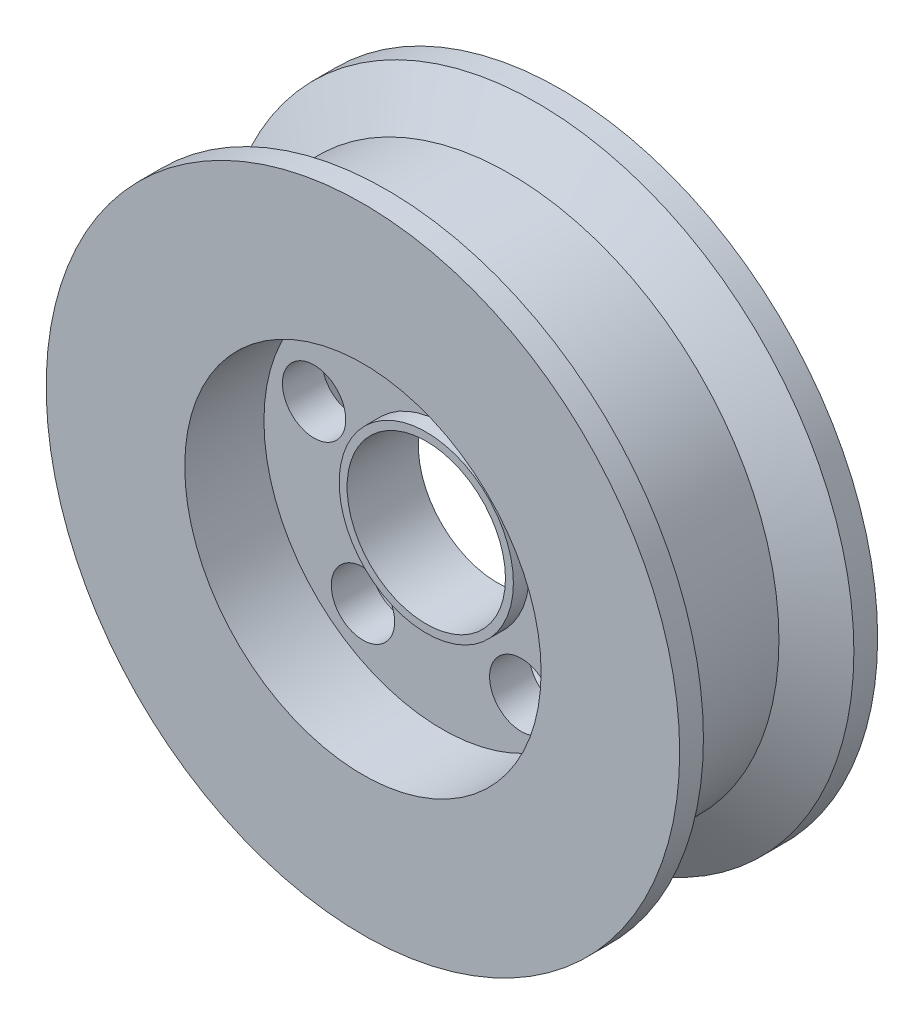
from build123d import *

# Parameters (mm, degrees)
SKETCH1_R                = 40
SKETCH1_R_2              = 10
BOSS_EXTRUDE1_DEPTH      = 12.5
SKETCH2_R                = 22.5
CUT_EXTRUDE1_DEPTH       = 10
SKETCH3_R                = 4
CUT_EXTRUDE2_DEPTH       = 16
CIRPATTERN1_COUNT        = 5
SKETCH4_R                = 11
SKETCH4_R_2              = 10
BOSS_EXTRUDE2_DEPTH      = 2
BOSS_EXTRUDE2_DEPTH_BACK = 7


with BuildPart() as part:
    # Sketch1 → Boss-Extrude1 (new body, symmetric)
    with BuildSketch(Plane.XY):
        Circle(SKETCH1_R)
        Circle(SKETCH1_R_2, mode=Mode.SUBTRACT)
    extrude(amount=BOSS_EXTRUDE1_DEPTH, both=True)

    # Sketch2 → Cut-Extrude1 (cut)
    with BuildSketch(Plane.XY.offset(12.5)):
        Circle(SKETCH2_R)
    cut_extrude1 = extrude(amount=-CUT_EXTRUDE1_DEPTH, mode=Mode.SUBTRACT)

    # Mirror1: Cut-Extrude1 across plane
    add(cut_extrude1.mirror(Plane.XY), mode=Mode.SUBTRACT)

    # Sketch3 → Cut-Extrude2 (cut, through all)
    with BuildSketch(Plane.XY.offset(2.5)):
        with Locations((0, 17)):
            Circle(SKETCH3_R)
    cut_extrude2 = extrude(amount=-CUT_EXTRUDE2_DEPTH, mode=Mode.SUBTRACT)

    # CirPattern1: Cut-Extrude2 ×5 about axis
    cirpattern1_axis = Axis((0, 0, 0), (0, 0, 1))
    for i in range(1, CIRPATTERN1_COUNT):
        add(cut_extrude2.rotate(cirpattern1_axis, i * 360 / CIRPATTERN1_COUNT), mode=Mode.SUBTRACT)

    # Sketch4 → Boss-Extrude2 (add, two sides)
    with BuildSketch(Plane.XY.offset(2.5)) as boss_extrude2_sk:
        Circle(SKETCH4_R)
        Circle(SKETCH4_R_2, mode=Mode.SUBTRACT)
    extrude(amount=BOSS_EXTRUDE2_DEPTH)
    extrude(boss_extrude2_sk.sketch, amount=-BOSS_EXTRUDE2_DEPTH_BACK)

    # Sketch5 → Cut-Revolve1 (revolve, cut)
    with BuildSketch(Plane(origin=(0, 0, 0), x_dir=(1, 0, 0), z_dir=(0, 1, 0))):
        Polygon((-40, 9.5), (-40, -9.5), (-34, -6.036086587), (-34, 6.035898385), align=None)
    revolve(axis=Axis((0, 0, 0), (0, 0, -1)), mode=Mode.SUBTRACT)


solid = part.part
